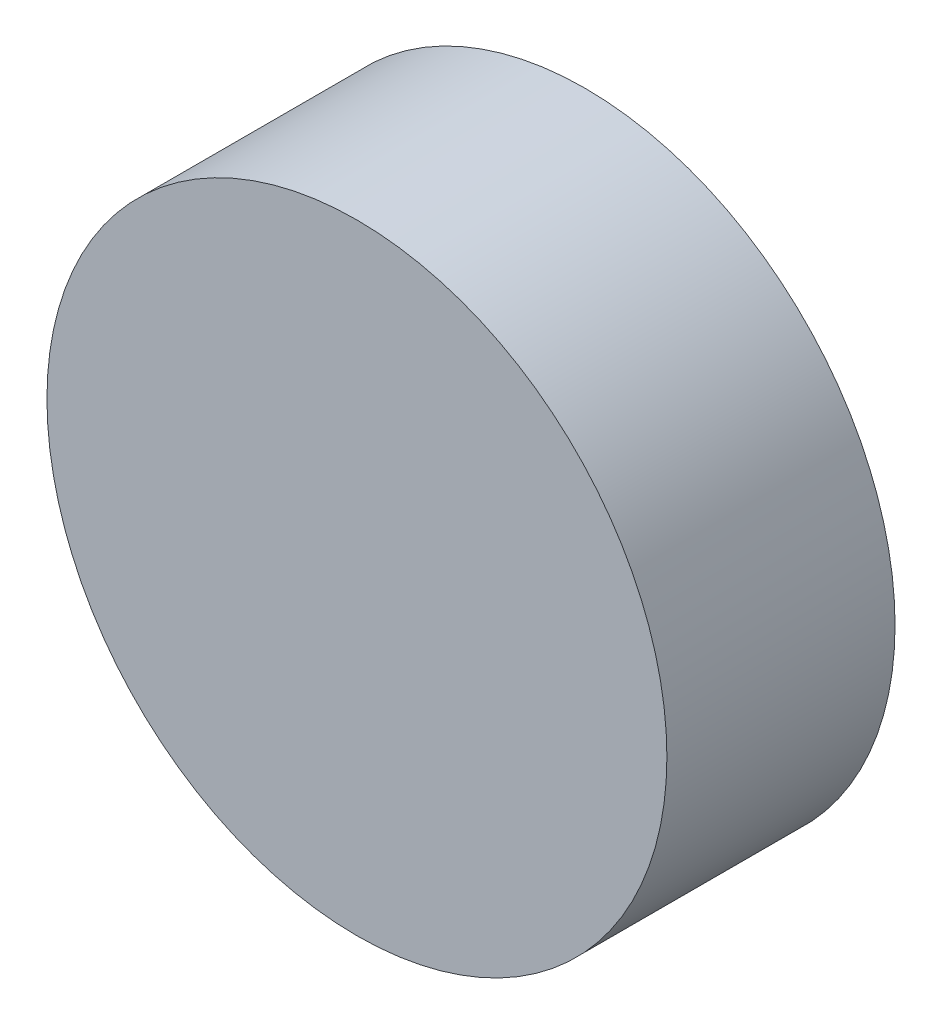
from build123d import *

# Parameters (mm, degrees)
SKETCH1_R           = 47.625
BOSS_EXTRUDE1_DEPTH = 35.052


with BuildPart() as part:
    # Sketch1 → Boss-Extrude1 (new body)
    with BuildSketch(Plane.XY):
        with Locations((-128.293417664, -1.503384342)):
            Circle(SKETCH1_R)
    extrude(amount=BOSS_EXTRUDE1_DEPTH)


solid = part.part
